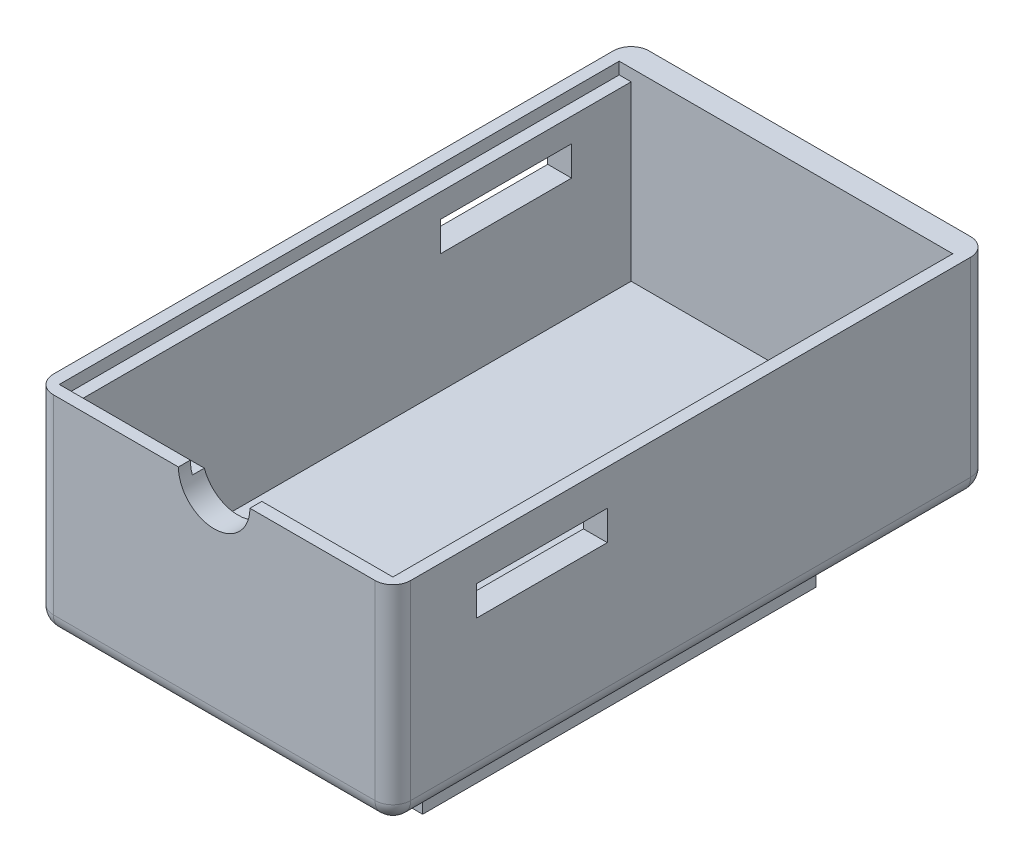
from build123d import *

# Parameters (mm, degrees)
BOSS_EXTRUDE1_DEPTH = 17.5
SHELL1_T            = -2
FILLET1_R           = 1.5
CUT_EXTRUDE3_REACH  = 4
SKETCH7_W           = 11
SKETCH7_H           = 2.5
CUT_EXTRUDE4_REACH  = 4
SKETCH8_W           = 11
SKETCH8_H           = 2.5
CUT_EXTRUDE5_DEPTH  = 1
CUT_EXTRUDE6_REACH  = 52
BOSS_EXTRUDE2_DEPTH = 6
FILLET2_R           = 2
FILLET3_R           = 1


with BuildPart() as part:
    # Sketch1 → Boss-Extrude1 (new body)
    with BuildSketch(Plane(origin=(0, 0, 0), x_dir=(1, 0, 0), z_dir=(0, 1, 0))):
        Polygon((-15, 20), (15, 20), (15, -20), (15, -30), (-15, -30), (-15, -20), align=None)
    extrude(amount=BOSS_EXTRUDE1_DEPTH)

    # Shell1
    shell1_openings = [part.faces().sort_by_distance(p)[0] for p in [
        (0, 17.5, 5),
    ]]
    offset(amount=SHELL1_T, openings=shell1_openings, kind=Kind.INTERSECTION)

    # Fillet1
    fillet1_edges = [part.edges().sort_by_distance(p)[0] for p in [
        (15, 8.75, 30),
        (-15, 8.75, 30),
        (-15, 8.75, -20),
        (15, 8.75, -20),
        (0, 0, 30),
        (-15, 0, 5),
        (0, 0, -20),
        (15, 0, 5),
    ]]
    fillet(fillet1_edges, radius=FILLET1_R)

    # Sketch7 → Cut-Extrude3 (cut, up to next)
    with BuildSketch(Plane.ZY.offset(-13), mode=Mode.PRIVATE) as cut_extrude3_sk1:
        with Locations((17.5, 13.25)):
            Rectangle(SKETCH7_W, SKETCH7_H)
    cut_extrude3_tool1 = extrude(cut_extrude3_sk1.sketch, amount=-CUT_EXTRUDE3_REACH, mode=Mode.PRIVATE) & part.part
    add(cut_extrude3_tool1.solids().sort_by_distance((13, 13.25, 17.5))[0], mode=Mode.SUBTRACT)

    # Sketch8 → Cut-Extrude4 (cut, up to next)
    with BuildSketch(Plane(origin=(-13, 0, 0), x_dir=(0, 0, -1), z_dir=(1, 0, 0)), mode=Mode.PRIVATE) as cut_extrude4_sk1:
        with Locations((7.5, 13.25)):
            Rectangle(SKETCH8_W, SKETCH8_H)
    cut_extrude4_tool1 = extrude(cut_extrude4_sk1.sketch, amount=-CUT_EXTRUDE4_REACH, mode=Mode.PRIVATE) & part.part
    add(cut_extrude4_tool1.solids().sort_by_distance((-13, 13.25, -7.5))[0], mode=Mode.SUBTRACT)

    # Sketch9 → Cut-Extrude5 (cut)
    with BuildSketch(Plane(origin=(0, 17.5, 0), x_dir=(1, 0, 0), z_dir=(0, 1, 0))):
        Polygon((-13, 18), (-14, 18), (-14, -19), (-14, -29), (14, -29), (14, -19), (14, 18), (13, 18), (13, -18), (13, -28), (-13, -28), (-13, -18), align=None)
    extrude(amount=-CUT_EXTRUDE5_DEPTH, mode=Mode.SUBTRACT)

    # Sketch10 → Cut-Extrude6 (cut, up to next)
    with BuildSketch(Plane.XY.offset(30), mode=Mode.PRIVATE) as cut_extrude6_sk1:
        with BuildLine():
            Line((-3, 17.5), (3, 17.5))
            ThreePointArc((3, 17.5), (0, 14.5), (-3, 17.5))
        make_face()
    cut_extrude6_tool1 = extrude(cut_extrude6_sk1.sketch, amount=-CUT_EXTRUDE6_REACH, mode=Mode.PRIVATE) & part.part
    add(cut_extrude6_tool1.solids().sort_by_distance((0, 16.22676, 30))[0], mode=Mode.SUBTRACT)

    # Sketch11 → Boss-Extrude2 (add)
    with BuildSketch(Plane.XZ):
        Polygon((-9, 21.5), (-9, -11.5), (6.25, -11.5), (9, -11.5), (9, 21.5), (7, 21.5), align=None)
        Polygon((-7, 5.524400968), (0, 5.524400968), (0, 8.324400968), (1, 8.324400968), (1, 5.524400968), (7, 5.524400968), (7, 12.524400968), (5.2, 12.524400968), (5.2, 13.524400968), (7, 13.524400968), (7, 19.524400968), (6.25, 19.524400968), (1, 19.524400968), (1, 17.724400968), (0, 17.724400968), (0, 19.524400968), (-7, 19.524400968), (-7, 13.524400968), (-4.2, 13.524400968), (-4.2, 12.524400968), (-7, 12.524400968), align=None, mode=Mode.SUBTRACT)
        Polygon((7.285005864, -9.5), (6.535005864, -9.5), (1.285005864, -9.5), (1.285005864, -7.7), (0.285005864, -7.7), (0.285005864, -9.5), (-6.714994136, -9.5), (-7, -9.5), (-7, -3.5), (-6.714994136, -3.5), (-3.914994136, -3.5), (-3.914994136, -2.475599032), (-7, -2.475599032), (-7, 4.524400968), (0, 4.524400968), (0, 1.724400968), (1, 1.724400968), (1, 4.524400968), (7.285005864, 4.524400968), (7.285005864, -2.5), (5.485005864, -2.5), (5.485005864, -3.5), (7.285005864, -3.5), align=None, mode=Mode.SUBTRACT)
    extrude(amount=BOSS_EXTRUDE2_DEPTH)

    # Fillet2
    fillet2_edges = [part.edges().sort_by_distance(p)[0] for p in [
        (-9, 0, 5),
        (0, 0, -11.5),
        (0, 0, 21.5),
        (9, 0, 5),
    ]]
    fillet(fillet2_edges, radius=FILLET2_R)

    # Fillet3
    fillet3_edges = [part.edges().sort_by_distance(p)[0] for p in [
        (0.785005864, -6, -7.7),
        (5.2, -6, 13.024400968),
        (0.5, -6, 8.324400968),
        (-4.2, -6, 13.024400968),
        (0.5, -6, 17.724400968),
        (-3.914994136, -6, -2.987799516),
        (0.5, -6, 1.724400968),
        (5.485005864, -6, -3),
    ]]
    fillet(fillet3_edges, radius=FILLET3_R)


solid = part.part
